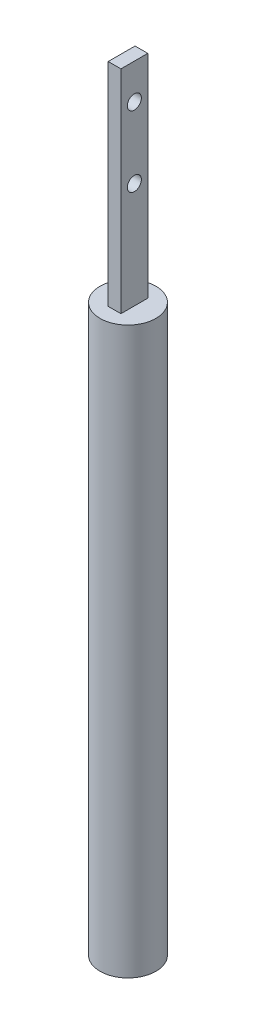
from build123d import *

# Parameters (mm, degrees)
SKETCH2_R           = 3.95
BOSS_EXTRUDE1_DEPTH = 80
SKETCH3_W           = 1.8
SKETCH3_H           = 3.8
BOSS_EXTRUDE3_DEPTH = 30
SKETCH5_R           = 1
CUT_EXTRUDE1_DEPTH  = 1.8


with BuildPart() as part:
    # Sketch2 → Boss-Extrude1 (new body)
    with BuildSketch(Plane(origin=(0, 0, 0), x_dir=(1, 0, 0), z_dir=(0, 1, 0))):
        with Locations(Location((0, 0, 0), (0, 0, 270))):  # turned: the seam where the file's is
            Circle(SKETCH2_R)
    extrude(amount=BOSS_EXTRUDE1_DEPTH)

    # Sketch3 → Boss-Extrude3 (add)
    with BuildSketch(Plane(origin=(0, 80, 0), x_dir=(1, 0, 0), z_dir=(0, 1, 0))):
        Rectangle(SKETCH3_W, SKETCH3_H)
    extrude(amount=BOSS_EXTRUDE3_DEPTH)

    # Sketch5 → Cut-Extrude1 (cut)
    with BuildSketch(Plane(origin=(0.9, 0, 0), x_dir=(0, 0, -1), z_dir=(1, 0, 0))):
        with Locations((0, 105)):
            Circle(SKETCH5_R)
        with Locations((0, 95)):
            Circle(SKETCH5_R)
    extrude(amount=-CUT_EXTRUDE1_DEPTH, mode=Mode.SUBTRACT)


solid = part.part
